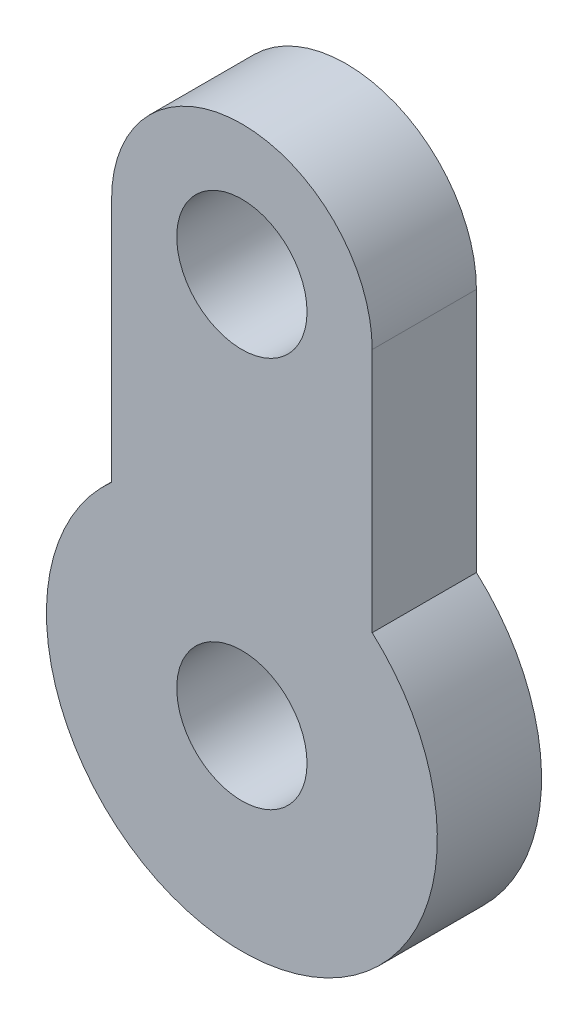
from build123d import *

# Parameters (mm, degrees)
SKETCH1_R           = 3.175
BOSS_EXTRUDE1_DEPTH = 5.08


with BuildPart() as part:
    # Sketch1 → Boss-Extrude1 (new body)
    with BuildSketch(Plane.XY):
        with BuildLine():
            Line((-6.35, 19.05), (-6.35, 7.099515829))
            ThreePointArc((-6.35, 7.099515829), (0, -9.525), (6.35, 7.099515829))
            Line((6.35, 7.099515829), (6.35, 19.05))
            ThreePointArc((6.35, 19.05), (0, 25.4), (-6.35, 19.05))
        make_face()
        with Locations((0, 19.05)):
            Circle(SKETCH1_R, mode=Mode.SUBTRACT)
        Circle(SKETCH1_R, mode=Mode.SUBTRACT)
    extrude(amount=BOSS_EXTRUDE1_DEPTH)


solid = part.part
